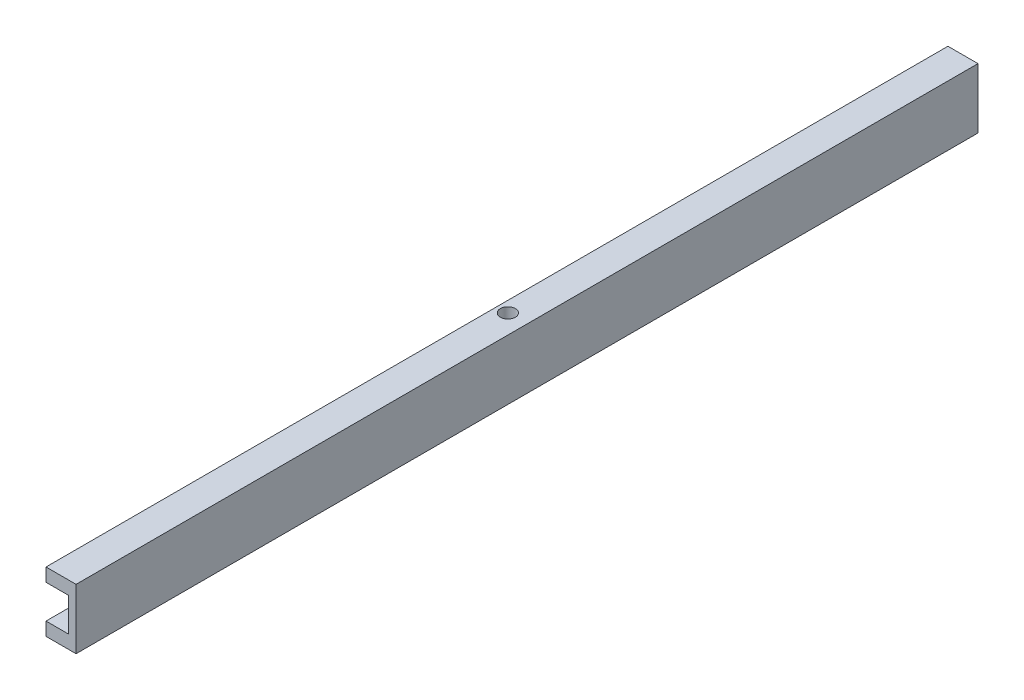
from build123d import *

# Parameters (mm, degrees)
BOSS_EXTRUDE1_DEPTH = 381
SKETCH2_R           = 3.175
CUT_EXTRUDE1_DEPTH  = 381


with BuildPart() as part:
    # Sketch1 → Boss-Extrude1 (new body)
    with BuildSketch(Plane.XY):
        Polygon((0, 25.4), (0, 19.787500049), (9.525, 19.787500049), (9.525, 5.612499951), (0, 5.612499951), (0, 0), (12.7, 0), (12.7, 25.4), align=None)
    extrude(amount=BOSS_EXTRUDE1_DEPTH)

    # Sketch2 → Cut-Extrude1 (cut)
    with BuildSketch(Plane(origin=(0, 25.4, 0), x_dir=(1, 0, 0), z_dir=(0, 1, 0))):
        with Locations((4.60375, -190.5)):
            Circle(SKETCH2_R)
    extrude(amount=-CUT_EXTRUDE1_DEPTH, mode=Mode.SUBTRACT)


solid = part.part
